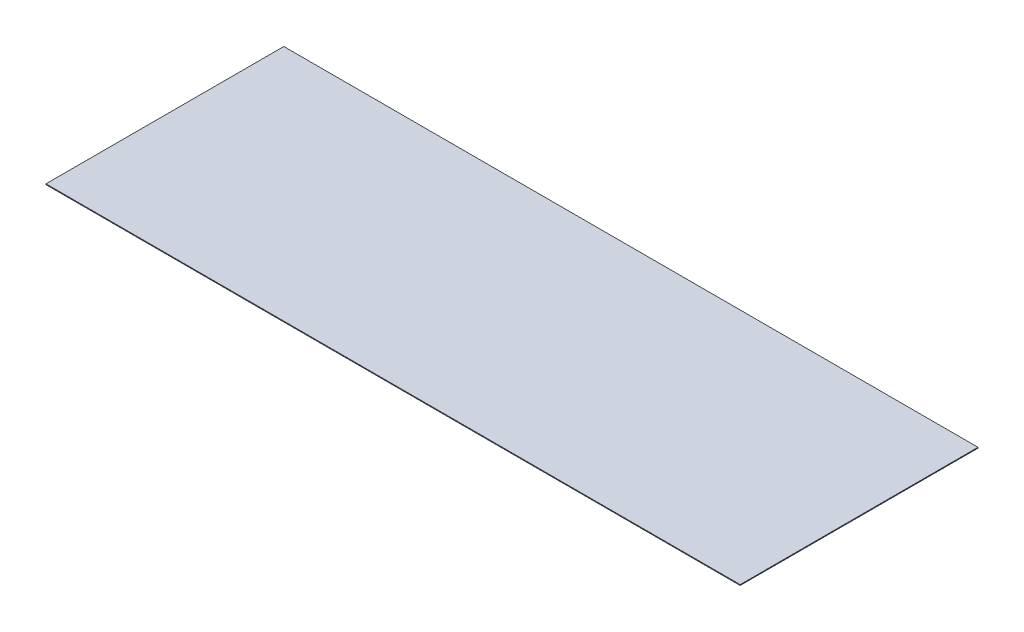
from build123d import *

# Parameters (mm, degrees)
SKETCH1_W           = 875.686
SKETCH1_H           = 300
BOSS_EXTRUDE1_DEPTH = 1


with BuildPart() as part:
    # Sketch1 → Boss-Extrude1 (new body)
    with BuildSketch(Plane(origin=(0, 0, 0), x_dir=(1, 0, 0), z_dir=(0, 1, 0))):
        Rectangle(SKETCH1_W, SKETCH1_H)
    extrude(amount=BOSS_EXTRUDE1_DEPTH)


solid = part.part
